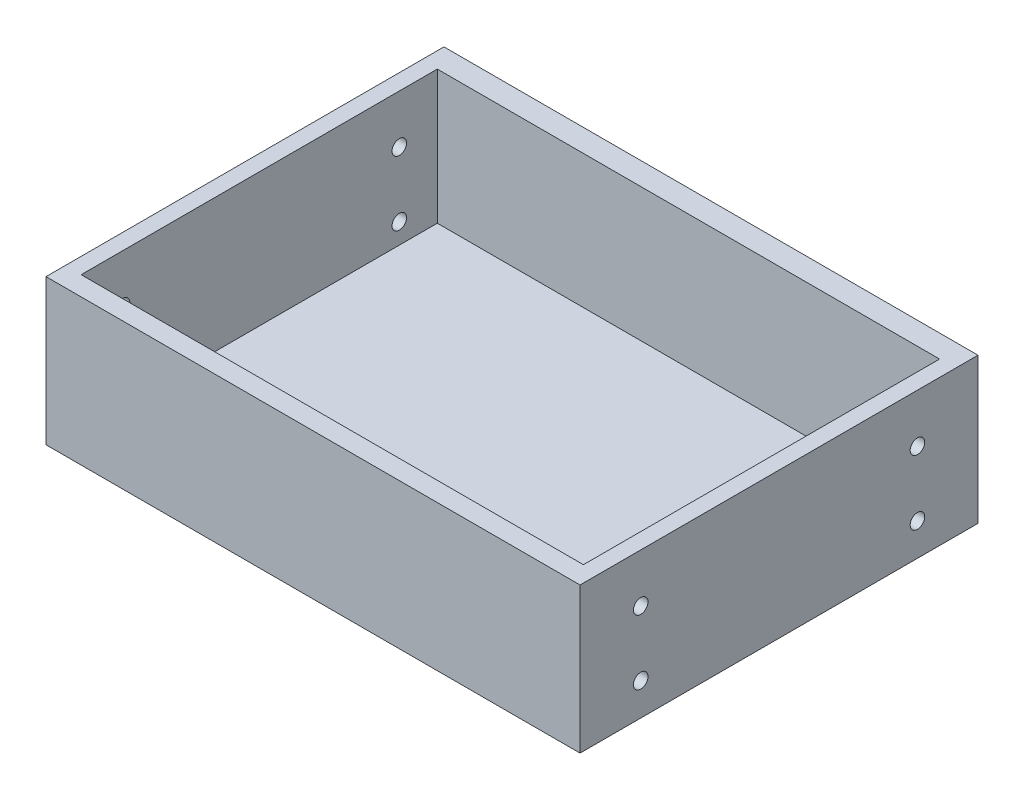
from build123d import *

# Parameters (mm, degrees)
SKETCH1_W           = 440
SKETCH1_H           = 327.889328918
BOSS_EXTRUDE1_DEPTH = 120
SKETCH8_W           = 413.828334862
SKETCH8_H           = 293.441910175
CUT_EXTRUDE1_DEPTH  = 110
SKETCH9_R           = 6
SKETCH9_R_2         = 6.017467881
CUT_EXTRUDE4_DEPTH  = 110
SKETCH10_R          = 6
SKETCH10_R_2        = 6.017467881
CUT_EXTRUDE5_DEPTH  = 110


with BuildPart() as part:
    # Sketch1 → Boss-Extrude1 (new body)
    with BuildSketch(Plane(origin=(0, 0, 0), x_dir=(1, 0, 0), z_dir=(0, 1, 0))):
        with Locations((-220, 163.944664459)):
            Rectangle(SKETCH1_W, SKETCH1_H)
    extrude(amount=BOSS_EXTRUDE1_DEPTH)

    # Sketch8 → Cut-Extrude1 (cut)
    with BuildSketch(Plane(origin=(0, 120, 0), x_dir=(1, 0, 0), z_dir=(0, 1, 0))):
        with Locations((-219.994628395, 162.587971533)):
            Rectangle(SKETCH8_W, SKETCH8_H)
    extrude(amount=-CUT_EXTRUDE1_DEPTH, mode=Mode.SUBTRACT)

    # Sketch9 → Cut-Extrude4 (cut)
    with BuildSketch(Plane(origin=(-426.908795826, 0, 0), x_dir=(0, 0, -1), z_dir=(1, 0, 0))):
        with Locations((278, 80)):
            Circle(SKETCH9_R)
        with Locations((278, 26.719560601)):
            Circle(SKETCH9_R)
        with Locations((50, 80)):
            Circle(SKETCH9_R)
        with Locations((50, 26.719560601)):
            Circle(SKETCH9_R_2)
    extrude(amount=-CUT_EXTRUDE4_DEPTH, mode=Mode.SUBTRACT)

    # Sketch10 → Cut-Extrude5 (cut)
    with BuildSketch(Plane(origin=(0, 0, 0), x_dir=(0, 0, -1), z_dir=(1, 0, 0))):
        with Locations((50, 80)):
            Circle(SKETCH10_R)
        with Locations((50, 26.719560601)):
            Circle(SKETCH10_R_2)
        with Locations((278, 26.719560601)):
            Circle(SKETCH10_R)
        with Locations((278, 80)):
            Circle(SKETCH10_R)
    extrude(amount=-CUT_EXTRUDE5_DEPTH, mode=Mode.SUBTRACT)


solid = part.part
